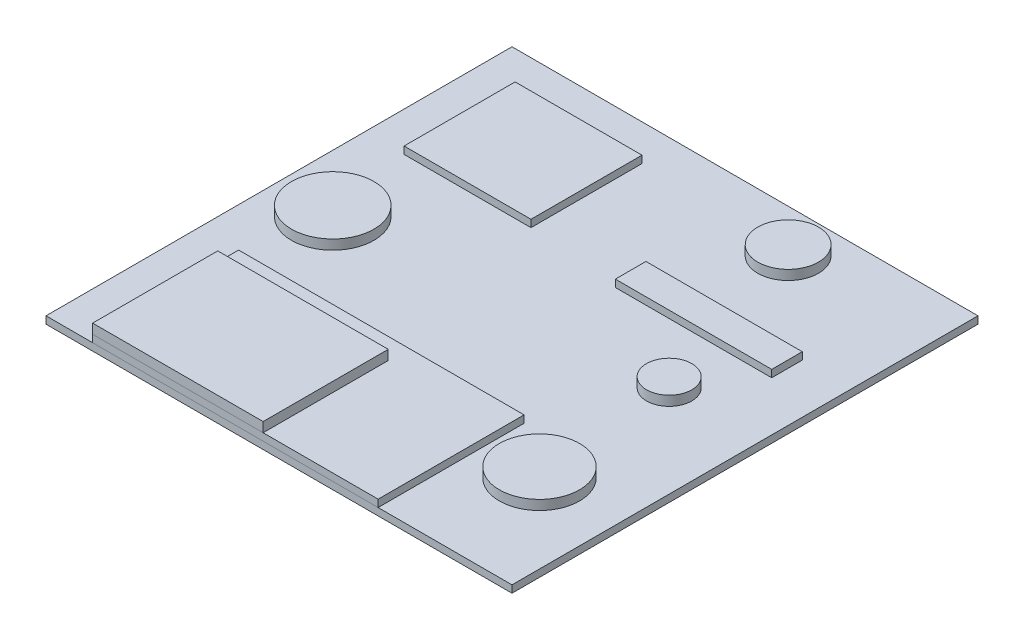
from build123d import *

# Parameters (mm, degrees)
SKETCH1_W        = 1219.2
SKETCH1_H        = 1219.2
EXTRUDE1_DEPTH   = 19.05
SKETCH2_W        = 331.947557721
SKETCH2_H        = 290.454113006
EXTRUDE2_DEPTH   = 19.05
SKETCH2_W_2      = 409.006812192
SKETCH2_H_2      = 80.02307195
EXTRUDE2_2_DEPTH = 19.05
SKETCH2_W_3      = 746.882004873
SKETCH2_H_3      = 381.921561998
EXTRUDE2_3_DEPTH = 19.05
SKETCH3_W        = 446.054530688
SKETCH3_H        = 327.296385063
EXTRUDE3_DEPTH   = 25.4
SKETCH4_R        = 107.935461677
EXTRUDE4_DEPTH   = 25.4
SKETCH4_R_2      = 59.276349593
EXTRUDE4_2_DEPTH = 25.4
SKETCH4_R_3      = 79.430861404
EXTRUDE4_3_DEPTH = 25.4
SKETCH4_R_4      = 104.975218643
EXTRUDE4_4_DEPTH = 25.4


with BuildPart() as part:
    # Sketch1 → Extrude1 (new body)
    with BuildSketch(Plane(origin=(0, 0, 0), x_dir=(1, 0, 0), z_dir=(0, 1, 0))):
        Rectangle(SKETCH1_W, SKETCH1_H)
    extrude(amount=EXTRUDE1_DEPTH)


with BuildPart() as body_2:
    # Sketch2 → Extrude2 (new body)
    with BuildSketch(Plane(origin=(0, 19.05, 0), x_dir=(1, 0, 0), z_dir=(0, 1, 0))):
        with Locations((-340.839010161, 369.736230587)):
            Rectangle(SKETCH2_W, SKETCH2_H)
    extrude(amount=EXTRUDE2_DEPTH)


with BuildPart() as body_3:
    # Sketch2 → Extrude2 2 (new body)
    with BuildSketch(Plane(origin=(0, 19.05, 0), x_dir=(1, 0, 0), z_dir=(0, 1, 0))):
        with Locations((275.635025608, 239.328261482)):
            Rectangle(SKETCH2_W_2, SKETCH2_H_2)
    extrude(amount=EXTRUDE2_2_DEPTH)


with BuildPart() as body_4:
    # Sketch2 → Extrude2 3 (new body)
    with BuildSketch(Plane(origin=(0, 19.05, 0), x_dir=(1, 0, 0), z_dir=(0, 1, 0))):
        with Locations((-114.106972966, -418.639219001)):
            Rectangle(SKETCH2_W_3, SKETCH2_H_3)
    extrude(amount=EXTRUDE2_3_DEPTH)


with BuildPart() as body_5:
    # Sketch3 → Extrude3 (new body)
    with BuildSketch(Plane(origin=(0, 38.1, 0), x_dir=(1, 0, 0), z_dir=(0, 1, 0))):
        with Locations((-264.520710059, -445.951807469)):
            Rectangle(SKETCH3_W, SKETCH3_H)
    extrude(amount=EXTRUDE3_DEPTH)


with BuildPart() as body_6:
    # Sketch4 → Extrude4 (new body)
    with BuildSketch(Plane(origin=(0, 19.05, 0), x_dir=(1, 0, 0), z_dir=(0, 1, 0))):
        with Locations(Location((-459.391709346, -9.632406809, 0), (0, 0, 270))):  # turned: the seam where the file's is
            Circle(SKETCH4_R)
    extrude(amount=EXTRUDE4_DEPTH)


with BuildPart() as body_7:
    # Sketch4 → Extrude4 2 (new body)
    with BuildSketch(Plane(origin=(0, 19.05, 0), x_dir=(1, 0, 0), z_dir=(0, 1, 0))):
        with Locations(Location((368.995276217, 42.234399085, 0), (0, 0, 270))):  # turned: the seam where the file's is
            Circle(SKETCH4_R_2)
    extrude(amount=EXTRUDE4_2_DEPTH)


with BuildPart() as body_8:
    # Sketch4 → Extrude4 3 (new body)
    with BuildSketch(Plane(origin=(0, 19.05, 0), x_dir=(1, 0, 0), z_dir=(0, 1, 0))):
        with Locations(Location((225.250128454, 497.180382212, 0), (0, 0, 270))):  # turned: the seam where the file's is
            Circle(SKETCH4_R_3)
    extrude(amount=EXTRUDE4_3_DEPTH)


with BuildPart() as body_9:
    # Sketch4 → Extrude4 4 (new body)
    with BuildSketch(Plane(origin=(0, 19.05, 0), x_dir=(1, 0, 0), z_dir=(0, 1, 0))):
        with Locations(Location((403.079177233, -331.206603351, 0), (0, 0, 270))):  # turned: the seam where the file's is
            Circle(SKETCH4_R_4)
    extrude(amount=EXTRUDE4_4_DEPTH)


solid = Compound([part.part, body_2.part, body_3.part, body_4.part, body_5.part, body_6.part, body_7.part, body_8.part, body_9.part])
